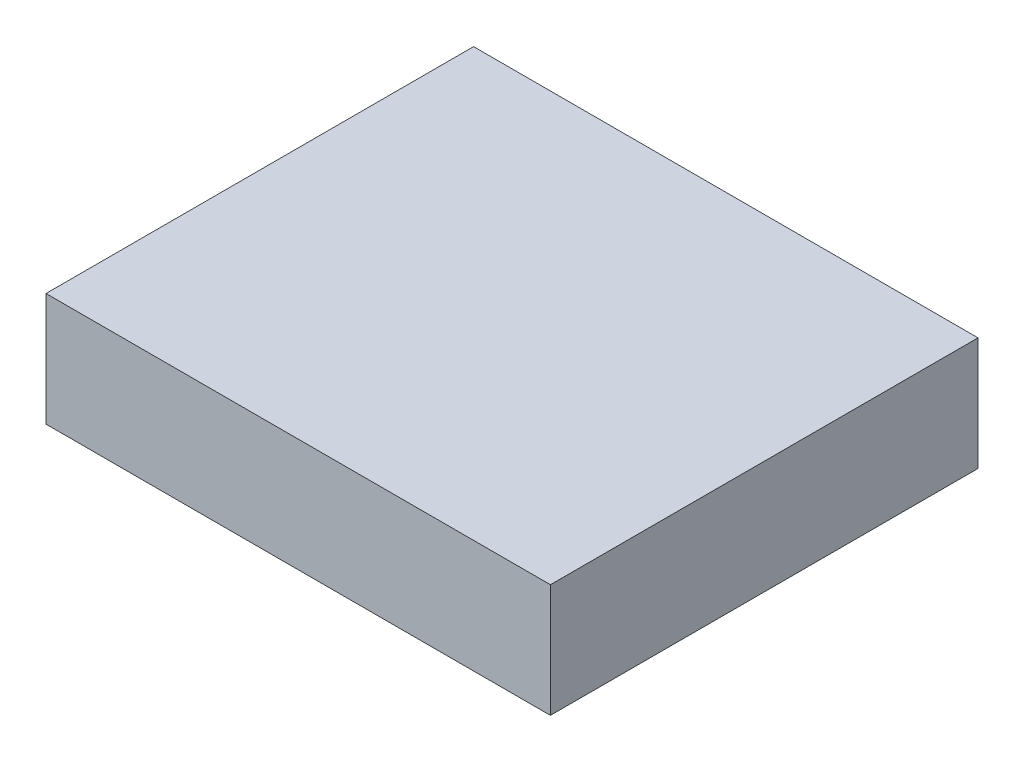
from build123d import *

# Parameters (mm, degrees)
SKETCH1_W           = 780
SKETCH1_H           = 661.213641652
BOSS_EXTRUDE1_DEPTH = 175


with BuildPart() as part:
    # Sketch1 → Boss-Extrude1 (new body)
    with BuildSketch(Plane(origin=(0, 0, 0), x_dir=(1, 0, 0), z_dir=(0, 1, 0))):
        Rectangle(SKETCH1_W, SKETCH1_H)
    extrude(amount=BOSS_EXTRUDE1_DEPTH)


solid = part.part
